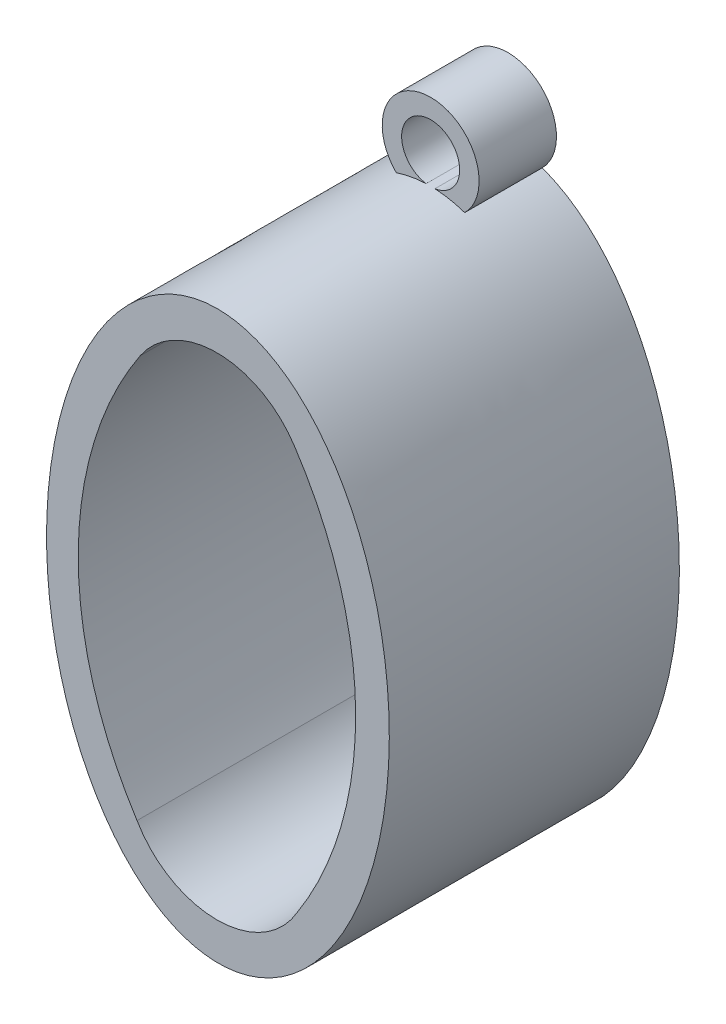
from build123d import *

# Parameters (mm, degrees)
ESQUISSE1_RX       = 14.645218004
ESQUISSE1_RY       = 8.862181001
BOSS_EXTRU_1_DEPTH = 15
ESQUISSE2_R        = 2.504582132
ESQUISSE2_R_2      = 1.5
BOSS_EXTRU_2_DEPTH = 4


with BuildPart() as part:
    # Esquisse1 → Boss.-Extru.1 (new body)
    with BuildSketch(Plane.XY):
        with Locations(Location((0, 0), (0, 0, 90.199055458))):
            Ellipse(ESQUISSE1_RX, ESQUISSE1_RY)
        with BuildLine():
            ThreePointArc((3.959542455, 10.480889746), (-0.016909511, 12.662493409), (-4.023209588, 10.536199809))
            ThreePointArc((-4.023209588, 10.536199809), (-7.222063109, 0.114609256), (-4.182661935, -10.354595777))
            ThreePointArc((-4.182661935, -10.354595777), (-0.046425778, -12.737390641), (4.086244093, -10.348415831))
            ThreePointArc((4.086244093, -10.348415831), (7.121864374, 0.085087548), (3.959542455, 10.480889746))
        make_face(mode=Mode.SUBTRACT)
    extrude(amount=BOSS_EXTRU_1_DEPTH)

    # Esquisse2 → Boss.-Extru.2 (add)
    with BuildSketch(Plane(origin=(0, 0, 0), x_dir=(-1, 0, 0), z_dir=(0, 0, -1))):
        with Locations((0, 16.123170266)):
            Circle(ESQUISSE2_R)
        with Locations((0, 16.123170266)):
            Circle(ESQUISSE2_R_2, mode=Mode.SUBTRACT)
    extrude(amount=-BOSS_EXTRU_2_DEPTH)


solid = part.part
